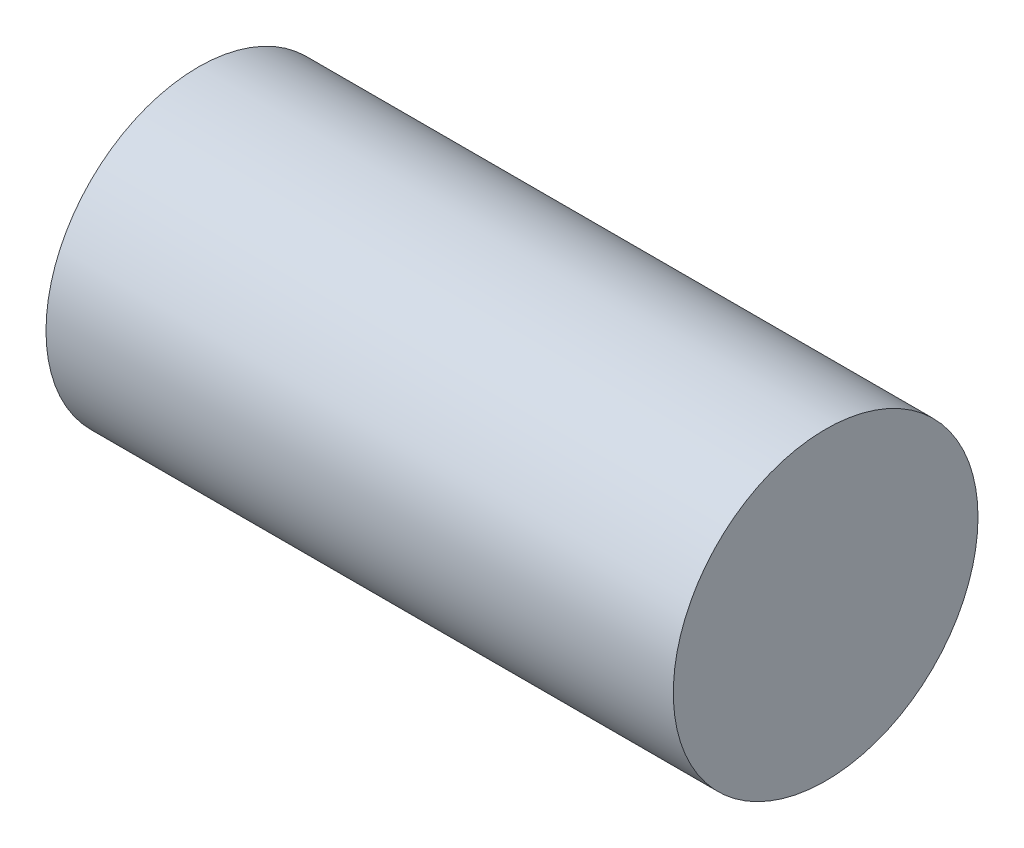
from build123d import *

# Parameters (mm, degrees)
SKETCH1_R           = 8.5
BOSS_EXTRUDE1_DEPTH = 31
SKETCH1_2_R         = 8.5
BOSS_EXTRUDE2_DEPTH = 2
SKETCH2_R           = 8.5
BOSS_EXTRUDE3_DEPTH = 2


with BuildPart() as part:
    # Sketch1 → Boss-Extrude1 (new body)
    with BuildSketch(Plane(origin=(0, 0, 0), x_dir=(0, 0, -1), z_dir=(1, 0, 0))):
        Circle(SKETCH1_R)
    extrude(amount=-BOSS_EXTRUDE1_DEPTH)

    # Sketch1_2 → Boss-Extrude2 (add)
    with BuildSketch(Plane(origin=(0, 0, 0), x_dir=(0, 0, -1), z_dir=(1, 0, 0))):
        Circle(SKETCH1_2_R)
    extrude(amount=BOSS_EXTRUDE2_DEPTH)

    # Sketch2 → Boss-Extrude3 (add)
    with BuildSketch(Plane.ZY.offset(31)):
        Circle(SKETCH2_R)
    extrude(amount=BOSS_EXTRUDE3_DEPTH)


solid = part.part
